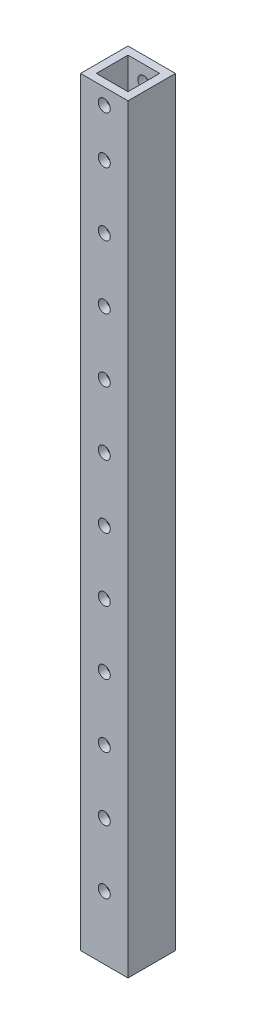
from build123d import *

# Parameters (mm, degrees)
SKETCH2_W           = 38.1
SKETCH2_H           = 38.1
SKETCH2_W_2         = 25.4
SKETCH2_H_2         = 25.4
BOSS_EXTRUDE1_DEPTH = 609.6
SKETCH3_R           = 4.826
CUT_EXTRUDE1_DEPTH  = 609.6


with BuildPart() as part:
    # Sketch2 → Boss-Extrude1 (new body)
    with BuildSketch(Plane(origin=(0, 0, 0), x_dir=(1, 0, 0), z_dir=(0, 1, 0))):
        Rectangle(SKETCH2_W, SKETCH2_H)
        Rectangle(SKETCH2_W_2, SKETCH2_H_2, mode=Mode.SUBTRACT)
    extrude(amount=BOSS_EXTRUDE1_DEPTH)

    # Sketch3 → Cut-Extrude1 (cut)
    with BuildSketch(Plane.XY.offset(19.05)):
        with Locations((0, 596.9)):
            Circle(SKETCH3_R)
        with Locations((0, 558.8)):
            Circle(SKETCH3_R)
        with Locations((0, 508)):
            Circle(SKETCH3_R)
        with Locations((0, 457.2)):
            Circle(SKETCH3_R)
        with Locations((0, 406.4)):
            Circle(SKETCH3_R)
        with Locations((0, 355.6)):
            Circle(SKETCH3_R)
        with Locations((0, 304.8)):
            Circle(SKETCH3_R)
        with Locations((0, 254)):
            Circle(SKETCH3_R)
        with Locations((0, 203.2)):
            Circle(SKETCH3_R)
        with Locations((0, 152.4)):
            Circle(SKETCH3_R)
        with Locations((0, 101.6)):
            Circle(SKETCH3_R)
        with Locations((0, 50.8)):
            Circle(SKETCH3_R)
    extrude(amount=-CUT_EXTRUDE1_DEPTH, mode=Mode.SUBTRACT)


solid = part.part
